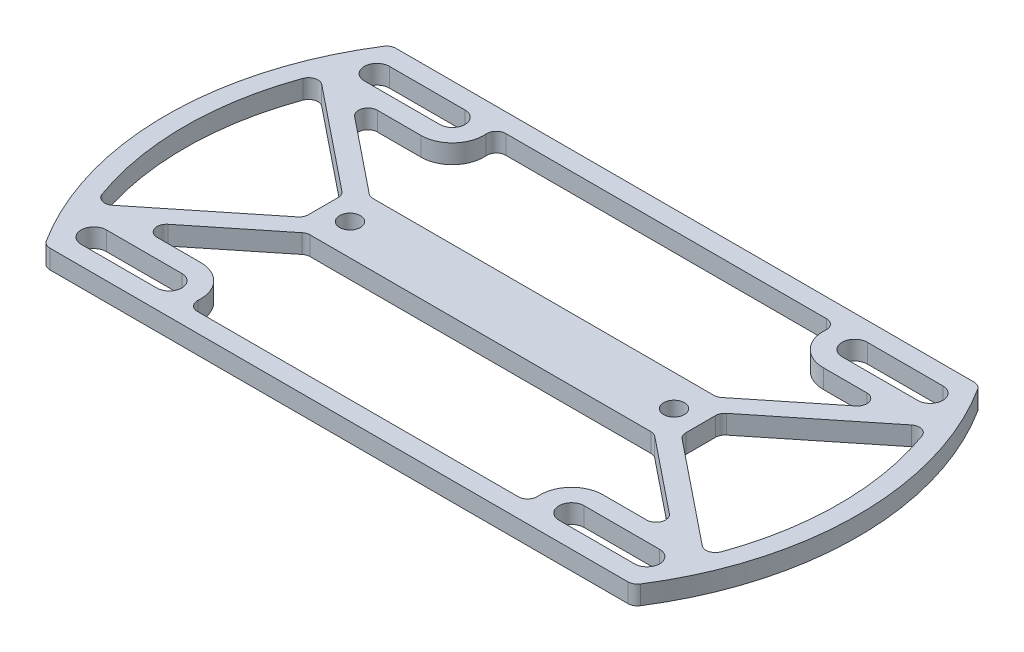
from build123d import *

# Parameters (mm, degrees)
EXTRUDE_1_DEPTH = 3
SKETCH_3_W      = 60
SKETCH_3_H      = 10
EXTRUDE_3_DEPTH = 3
EXTRUDE_4_DEPTH = 3
EXTRUDE_5_DEPTH = 3
FILLET_1_R      = 1.5
FILLET_2_R      = 1.5
M4X0_71_D       = 3.3


with BuildPart() as part:
    # Эскиз1 → Бобышка-Вытянуть1 (new body)
    with BuildSketch(Plane(origin=(0, 0, 0), x_dir=(1, 0, 0), z_dir=(0, 1, 0))):
        with BuildLine():
            Line((8.241767279, 0), (101.758232721, 0))
            ThreePointArc((101.758232721, 0), (110, 27.5), (101.758232721, 55))
            Line((101.758232721, 55), (8.241767279, 55))
            ThreePointArc((8.241767279, 55), (0, 27.5), (8.241767279, 0))
        make_face()
        with BuildLine():
            Line((9.890774129, 3), (100.109225871, 3))
            ThreePointArc((100.109225871, 3), (107, 27.5), (100.109225871, 52))
            Line((100.109225871, 52), (9.890774129, 52))
            ThreePointArc((9.890774129, 52), (3, 27.5), (9.890774129, 3))
        make_face(mode=Mode.SUBTRACT)
    extrude(amount=EXTRUDE_1_DEPTH)

    # Эскиз4 → Бобышка-Вытянуть4 (add, through all)
    with BuildSketch(Plane.XZ):
        with BuildLine():
            Line((27.611432525, -3), (23.02885683, -3))
            ThreePointArc((23.02885683, -3), (25.02885683, -5), (23.02885683, -7))
            Line((23.02885683, -7), (11.02885683, -7))
            ThreePointArc((11.02885683, -7), (9.296806041, -6.000000032), (9.296805985, -4.000000064))
            ThreePointArc((9.296805985, -4.000000064), (8.176529623, -6.057114801), (7.160134889, -8.167489628))
            ThreePointArc((7.160134889, -8.167489628), (8.888465293, -9.51870823), (11.02885683, -10))
            Line((11.02885683, -10), (23.02885683, -10))
            ThreePointArc((23.02885683, -10), (27.212156962, -7.738612788), (27.611432525, -3))
        make_face()
        with BuildLine():
            ThreePointArc((9.296805985, -4.000000064), (10.028856798, -3.267949211), (11.02885683, -3))
            Line((11.02885683, -3), (9.890774129, -3))
            ThreePointArc((9.890774129, -3), (9.590696591, -3.498162612), (9.296805985, -4.000000064))
        make_face()
        with BuildLine():
            Line((86.97114317, -3), (82.388567475, -3))
            ThreePointArc((82.388567475, -3), (82.787843038, -7.738612788), (86.97114317, -10))
            Line((86.97114317, -10), (98.97114317, -10))
            ThreePointArc((98.97114317, -10), (101.111534707, -9.51870823), (102.839865111, -8.167489628))
            ThreePointArc((102.839865111, -8.167489628), (101.823470359, -6.057114766), (100.703193976, -3.999999997))
            ThreePointArc((100.703193976, -3.999999997), (100.703193979, -5.999999998), (98.97114317, -7))
            Line((98.97114317, -7), (86.97114317, -7))
            ThreePointArc((86.97114317, -7), (84.97114317, -5), (86.97114317, -3))
        make_face()
        with BuildLine():
            Line((100.109225871, -3), (98.97114317, -3))
            ThreePointArc((98.97114317, -3), (99.971143169, -3.267949191), (100.703193976, -3.999999997))
            ThreePointArc((100.703193976, -3.999999997), (100.409303389, -3.498162579), (100.109225871, -3))
        make_face()
        with BuildLine():
            ThreePointArc((100.703194034, -50.999999903), (101.823470385, -48.942885182), (102.839865111, -46.832510372))
            ThreePointArc((102.839865111, -46.832510372), (101.111534707, -45.48129177), (98.97114317, -45))
            Line((98.97114317, -45), (86.97114317, -45))
            ThreePointArc((86.97114317, -45), (82.787843038, -47.261387212), (82.388567475, -52))
            Line((82.388567475, -52), (86.97114317, -52))
            ThreePointArc((86.97114317, -52), (84.97114317, -50), (86.97114317, -48))
            Line((86.97114317, -48), (98.97114317, -48))
            ThreePointArc((98.97114317, -48), (100.70319395, -48.999999951), (100.703194034, -50.999999903))
        make_face()
        with BuildLine():
            ThreePointArc((100.109225871, -52), (100.409303419, -51.501837371), (100.703194034, -50.999999903))
            ThreePointArc((100.703194034, -50.999999903), (99.971143219, -51.732050779), (98.97114317, -52))
            Line((98.97114317, -52), (100.109225871, -52))
        make_face()
        with BuildLine():
            ThreePointArc((11.02885683, -45), (8.888465293, -45.48129177), (7.160134889, -46.832510372))
            ThreePointArc((7.160134889, -46.832510372), (8.17652965, -48.942885251), (9.296806044, -51.000000038))
            ThreePointArc((9.296806044, -51.000000038), (9.296806011, -49.000000019), (11.02885683, -48))
            Line((11.02885683, -48), (23.02885683, -48))
            ThreePointArc((23.02885683, -48), (25.02885683, -50), (23.02885683, -52))
            Line((23.02885683, -52), (27.611432525, -52))
            ThreePointArc((27.611432525, -52), (27.212156962, -47.261387212), (23.02885683, -45))
            Line((23.02885683, -45), (11.02885683, -45))
        make_face()
        with BuildLine():
            ThreePointArc((11.02885683, -52), (10.028856848, -51.732050818), (9.296806044, -51.000000038))
            ThreePointArc((9.296806044, -51.000000038), (9.590696621, -51.501837438), (9.890774129, -52))
            Line((9.890774129, -52), (11.02885683, -52))
        make_face()
    extrude(amount=-EXTRUDE_4_DEPTH)



with BuildPart() as body_2:
    # Эскиз3 → Бобышка-Вытянуть3 (new body, through all)
    with BuildSketch(Plane.XZ):
        with Locations((55, -27.5)):
            Rectangle(SKETCH_3_W, SKETCH_3_H)
    extrude(amount=-EXTRUDE_3_DEPTH)


with BuildPart() as part_1:
    add(part.part)

    add(body_2.part)  # Бобышка-Вытянуть5 merges body 2
    # Эскиз5 → Бобышка-Вытянуть5 (add, through all)
    with BuildSketch(Plane.XZ):
        Polygon((27.394984288, -22.5), (8.099598255, -6.998127159), (6.220671523, -9.336852098), (25, -24.424125375), (25, -22.5), align=None)
        Polygon((25, -30.575874625), (6.220671523, -45.663147902), (8.099598255, -48.001872841), (27.394984288, -32.5), (25, -32.5), align=None)
        Polygon((101.900401745, -6.998127159), (82.605015712, -22.5), (85, -22.5), (85, -24.424125375), (103.779328477, -9.336852098), align=None)
        Polygon((82.605015712, -32.5), (101.900401745, -48.001872841), (103.779328477, -45.663147902), (85, -30.575874625), (85, -32.5), align=None)
    extrude(amount=-EXTRUDE_5_DEPTH)

    # Скругление1
    fillet_1_edges = [part_1.edges().sort_by_distance(p)[0] for p in [
        (11.836069059, 1.5, -45),
        (6.543612581, 1.5, -45.403697731),
        (27.394984288, 1.5, -32.5),
        (25, 1.5, -30.575874625),
        (98.163930941, 1.5, -10),
        (103.456387419, 1.5, -9.596302269),
        (82.605015712, 1.5, -22.5),
        (85, 1.5, -24.424125375),
        (27.394984288, 1.5, -22.5),
        (98.163930941, 1.5, -45),
        (103.456387419, 1.5, -45.403697731),
        (25, 1.5, -24.424125375),
        (82.605015712, 1.5, -32.5),
        (85, 1.5, -30.575874625),
        (11.836069059, 1.5, -10),
        (6.543612581, 1.5, -9.596302269),
        (27.611432525, 1.5, -52),
        (82.388567475, 1.5, -3),
        (27.611432525, 1.5, -3),
        (82.388567475, 1.5, -52),
    ]]
    fillet(fillet_1_edges, radius=FILLET_1_R)

    # Скругление2
    fillet_2_edges = [part_1.edges().sort_by_distance(p)[0] for p in [
        (8.241767279, 1.5, -55),
        (8.241767279, 1.5, 0),
        (101.758232721, 1.5, 0),
        (101.758232721, 1.5, -55),
    ]]
    fillet(fillet_2_edges, radius=FILLET_2_R)

    # Отверстие обработанное метчиком M4x0.71 (through all)
    with Locations(Plane(origin=(-0.1210586, 0, 3.198200318), x_dir=(-1, 0, 0), z_dir=(0, -1, 0))):
        with Locations((-80.8710586, 30.698200318), (-29.3710586, 30.698200318)):
            Hole(M4X0_71_D / 2)


solid = part_1.part
